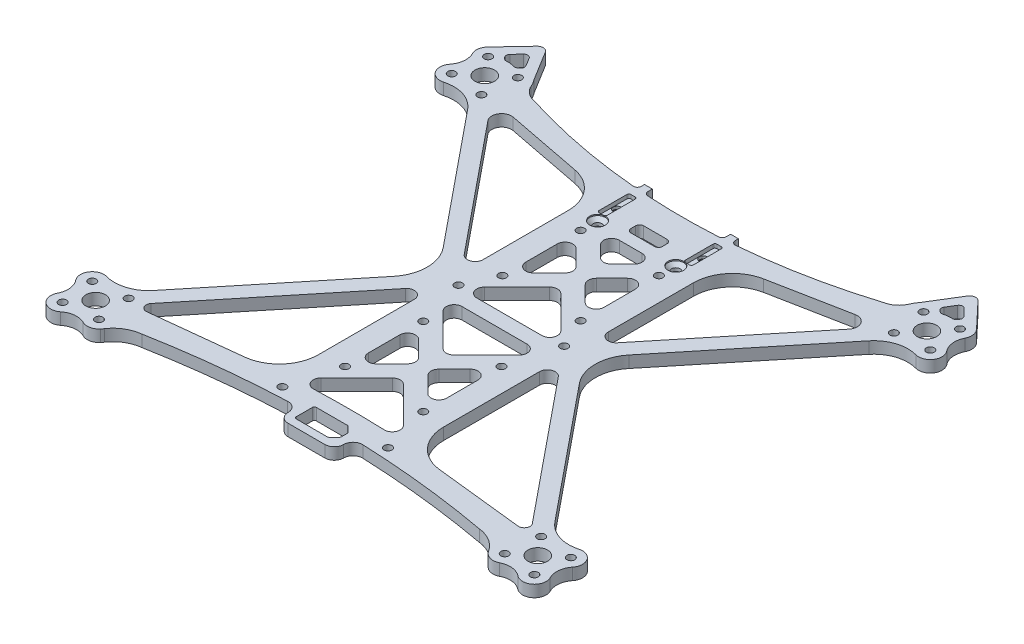
from build123d import *

# Parameters (mm, degrees)
SKETCH1_R                                      = 1
BASE_SHAPE_DEPTH                               = 2
CAMERA_MOUNT_POCKETS_DEPTH                     = 1
SKETCH3_R                                      = 1
THICKER_BASE_DEPTH                             = 1
SKETCH8_R                                      = 1
THICKER_CAMERA_MOUNT_POCKET_DEPTH              = 1
BATTERY_HOLDER_POCKETS_DEPTH                   = 1
BATTERY_HOLDER_HOLES_REACH                     = 55.417
SKETCH5_R                                      = 1.1
SKETCH7_R                                      = 1
SKETCH7_R_2                                    = 2.5
ARMS_DEPTH                                     = 3
MOTOR_PROTECTOR_FILLETS_R                      = 1
MOTOR_PROTECTOR_FILLETS_OF_ARMS_MIRROR_R       = 1
ARM_FILLETS_OUTER_R                            = 10
ARM_FILLETS_INNER_R                            = 2
ARM_LARGE_RADIUSES_REACH                       = 97.129
SKETCH11_W                                     = 2
SKETCH11_H                                     = 2.051249888
CAMERA_MOUNT_EXTENSION_DEPTH                   = 3
CAMERA_MOUNT_EXTENSION_FILLETS_R               = 1
CSK_FOR_M2_FLAT_HEAD_MACHINE_SCREW2_AT_2_COUNT = 2
CSK_FOR_M2_FLAT_HEAD_MACHINE_SCREW2_AT_2_PITCH = 22
CSK_FOR_M2_FLAT_HEAD_MACHINE_SCREW2_AT_3_COUNT = 2
CSK_FOR_M2_FLAT_HEAD_MACHINE_SCREW2_AT_3_PITCH = 10.373313116
CSK_FOR_M2_FLAT_HEAD_MACHINE_SCREW2_AT_4_COUNT = 2
CSK_FOR_M2_FLAT_HEAD_MACHINE_SCREW2_AT_4_PITCH = 23.400974873
CSK_FOR_M2_FLAT_HEAD_MACHINE_SCREW2_AT_5_COUNT = 2
CSK_FOR_M2_FLAT_HEAD_MACHINE_SCREW2_AT_5_PITCH = 30.341483566
CSK_FOR_M2_FLAT_HEAD_MACHINE_SCREW2_AT_6_COUNT = 2
CSK_FOR_M2_FLAT_HEAD_MACHINE_SCREW2_AT_6_PITCH = 36.886388072
CSK_FOR_M2_FLAT_HEAD_MACHINE_SCREW2_AT_7_COUNT = 2
CSK_FOR_M2_FLAT_HEAD_MACHINE_SCREW2_AT_7_PITCH = 50.559890229
CSK_FOR_M2_FLAT_HEAD_MACHINE_SCREW2_AT_8_COUNT = 2
CSK_FOR_M2_FLAT_HEAD_MACHINE_SCREW2_AT_8_PITCH = 54.738491941
CSK_FOR_M2_FLAT_HEAD_MACHINE_SCREW2_AT_9_COUNT = 2
CSK_FOR_M2_FLAT_HEAD_MACHINE_SCREW2_AT_9_PITCH = 70.557086816
CSK_FOR_M2_FLAT_HEAD_MACHINE_SCREW2_AT_1_COUNT = 2
CSK_FOR_M2_FLAT_HEAD_MACHINE_SCREW2_AT_1_PITCH = 73.60911968
CSK_FOR_M2_FLAT_HEAD_MACHINE_SCREW2_2_COUNT    = 2
CSK_FOR_M2_FLAT_HEAD_MACHINE_SCREW2_2_PITCH    = 38.132040334
CSK_FOR_M2_FLAT_HEAD_MACHINE_SCREW2_3_COUNT    = 2
CSK_FOR_M2_FLAT_HEAD_MACHINE_SCREW2_3_PITCH    = 45.255414041
CSK_FOR_M2_FLAT_HEAD_MACHINE_SCREW2_4_COUNT    = 2
CSK_FOR_M2_FLAT_HEAD_MACHINE_SCREW2_4_PITCH    = 83.087619415
CSK_FOR_M2_FLAT_HEAD_MACHINE_SCREW2_5_COUNT    = 2
CSK_FOR_M2_FLAT_HEAD_MACHINE_SCREW2_5_PITCH    = 86.588408578
CSK_FOR_M2_FLAT_HEAD_MACHINE_SCREW3_AT_2_COUNT = 2
CSK_FOR_M2_FLAT_HEAD_MACHINE_SCREW3_AT_2_PITCH = 20
GPS_CONNECTOR_HOLE_REACH                       = 97.129
TOP_WEIGHT_CUTS_REACH                          = 97.129
SKETCH29_W                                     = 14.2
SKETCH29_H                                     = 5
XT30_MATERIAL_DEPTH                            = 3
XT30_CUT_REACH                                 = 97.129
XT30_OUTSIDE_FILLETS_R                         = 2.4
XT30_INSIDE_FILLETS_R                          = 0.5


with BuildPart() as part:
    # Sketch1 → Base shape (new body)
    with BuildSketch(Plane(origin=(0, 0, 0), x_dir=(1, 0, 0), z_dir=(0, 1, 0))):
        with BuildLine():
            Line((-16, 47.925), (-16, -38.225))
            ThreePointArc((-16, -38.225), (-15.267766956, -39.99276695), (-13.500000008, -40.725))
            Line((-13.500000008, -40.725), (13.5, -40.725))
            ThreePointArc((13.5, -40.725), (15.267766953, -39.992766953), (16, -38.225))
            Line((16, -38.225), (16, 47.925))
            ThreePointArc((16, 47.925), (15.121320344, 50.046320344), (13, 50.925))
            Line((13, 50.925), (-13, 50.925))
            ThreePointArc((-13, 50.925), (-15.121320344, 50.046320344), (-16, 47.925))
        make_face()
        with Locations(Location((-13.5, -38.225, 0), (0, 0, 270))):
            Circle(SKETCH1_R, mode=Mode.SUBTRACT)
        with Locations(Location((13.5, -38.225, 0), (0, 0, 270))):
            Circle(SKETCH1_R, mode=Mode.SUBTRACT)
        with Locations(Location((10, -25.725, 0), (0, 0, 270))):
            Circle(SKETCH1_R, mode=Mode.SUBTRACT)
        with Locations(Location((-10, -25.725, 0), (0, 0, 270))):
            Circle(SKETCH1_R, mode=Mode.SUBTRACT)
        with Locations(Location((-10, -5.725, 0), (0, 0, 270))):
            Circle(SKETCH1_R, mode=Mode.SUBTRACT)
        with Locations(Location((10, -5.725, 0), (0, 0, 270))):
            Circle(SKETCH1_R, mode=Mode.SUBTRACT)
        with Locations(Location((-11, 44.825, 0), (0, 0, 270))):
            Circle(SKETCH1_R, mode=Mode.SUBTRACT)
        with Locations(Location((-10, 34.5, 0), (0, 0, 270))):
            Circle(SKETCH1_R, mode=Mode.SUBTRACT)
        with Locations(Location((10, 34.5, 0), (0, 0, 270))):
            Circle(SKETCH1_R, mode=Mode.SUBTRACT)
        with Locations(Location((10, 14.5, 0), (0, 0, 270))):
            Circle(SKETCH1_R, mode=Mode.SUBTRACT)
        with Locations(Location((-10, 14.5, 0), (0, 0, 270))):
            Circle(SKETCH1_R, mode=Mode.SUBTRACT)
        with Locations(Location((13.5, 6.775, 0), (0, 0, 270))):
            Circle(SKETCH1_R, mode=Mode.SUBTRACT)
        with Locations(Location((11, 44.825, 0), (0, 0, 270))):
            Circle(SKETCH1_R, mode=Mode.SUBTRACT)
        with Locations(Location((-13.5, 6.775, 0), (0, 0, 270))):
            Circle(SKETCH1_R, mode=Mode.SUBTRACT)
    extrude(amount=BASE_SHAPE_DEPTH)

    # Sketch2 → Camera mount pockets (cut)
    with BuildSketch(Plane.XZ.offset(-2)):
        with BuildLine():
            Line((11.55, -40.775), (10.45, -40.775))
            ThreePointArc((10.45, -40.775), (10.096446609, -40.921446609), (9.95, -41.275))
            Line((9.95, -41.275), (9.95, -48.375))
            ThreePointArc((9.95, -48.375), (10.096446609, -48.728553391), (10.45, -48.875))
            Line((10.45, -48.875), (11.55, -48.875))
            ThreePointArc((11.55, -48.875), (11.903553391, -48.728553391), (12.05, -48.375))
            Line((12.05, -48.375), (12.05, -41.275))
            ThreePointArc((12.05, -41.275), (11.903553391, -40.921446609), (11.55, -40.775))
        make_face()
        with BuildLine():
            Line((-11.55, -40.775), (-10.45, -40.775))
            ThreePointArc((-10.45, -40.775), (-10.096446609, -40.921446609), (-9.95, -41.275))
            Line((-9.95, -41.275), (-9.95, -48.375))
            ThreePointArc((-9.95, -48.375), (-10.096446609, -48.728553391), (-10.45, -48.875))
            Line((-10.45, -48.875), (-11.55, -48.875))
            ThreePointArc((-11.55, -48.875), (-11.903553391, -48.728553391), (-12.05, -48.375))
            Line((-12.05, -48.375), (-12.05, -41.275))
            ThreePointArc((-12.05, -41.275), (-11.903553391, -40.921446609), (-11.55, -40.775))
        make_face()
    extrude(amount=CAMERA_MOUNT_POCKETS_DEPTH, mode=Mode.SUBTRACT)

    # Sketch3 → Thicker base (add)
    with BuildSketch(Plane(origin=(0, 2, 0), x_dir=(1, 0, 0), z_dir=(0, 1, 0))):
        with BuildLine():
            Line((-16, 47.925), (-16, -38.225))
            ThreePointArc((-16, -38.225), (-15.267766953, -39.992766953), (-13.5, -40.725))
            Line((-13.5, -40.725), (13.5, -40.725))
            ThreePointArc((13.5, -40.725), (15.267766953, -39.992766953), (16, -38.225))
            Line((16, -38.225), (16, 47.925))
            ThreePointArc((16, 47.925), (15.121320344, 50.046320344), (13, 50.925))
            Line((13, 50.925), (-13, 50.925))
            ThreePointArc((-13, 50.925), (-15.121320344, 50.046320344), (-16, 47.925))
        make_face()
        with Locations(Location((10, 14.5, 0), (0, 0, 270))):
            Circle(SKETCH3_R, mode=Mode.SUBTRACT)
        with Locations(Location((10, 34.5, 0), (0, 0, 270))):
            Circle(SKETCH3_R, mode=Mode.SUBTRACT)
        with Locations(Location((-10, 34.5, 0), (0, 0, 270))):
            Circle(SKETCH3_R, mode=Mode.SUBTRACT)
        with Locations(Location((-10, 14.5, 0), (0, 0, 270))):
            Circle(SKETCH3_R, mode=Mode.SUBTRACT)
        with Locations(Location((13.5, 6.775, 0), (0, 0, 270))):
            Circle(SKETCH3_R, mode=Mode.SUBTRACT)
        with Locations(Location((10, -5.725, 0), (0, 0, 270))):
            Circle(SKETCH3_R, mode=Mode.SUBTRACT)
        with Locations(Location((10, -25.725, 0), (0, 0, 270))):
            Circle(SKETCH3_R, mode=Mode.SUBTRACT)
        with Locations(Location((-10, -25.725, 0), (0, 0, 270))):
            Circle(SKETCH3_R, mode=Mode.SUBTRACT)
        with Locations(Location((-10, -5.725, 0), (0, 0, 270))):
            Circle(SKETCH3_R, mode=Mode.SUBTRACT)
        with Locations(Location((13.5, -38.225, 0), (0, 0, 270))):
            Circle(SKETCH3_R, mode=Mode.SUBTRACT)
        with Locations(Location((-13.5, -38.225, 0), (0, 0, 270))):
            Circle(SKETCH3_R, mode=Mode.SUBTRACT)
        with Locations(Location((-13.5, 6.775, 0), (0, 0, 270))):
            Circle(SKETCH3_R, mode=Mode.SUBTRACT)
        with BuildLine():
            Line((-11.55, 48.875), (-10.45, 48.875))
            ThreePointArc((-10.45, 48.875), (-10.096446609, 48.728553391), (-9.95, 48.375))
            Line((-9.95, 48.375), (-9.95, 41.275))
            ThreePointArc((-9.95, 41.275), (-10.096446609, 40.921446609), (-10.45, 40.775))
            Line((-10.45, 40.775), (-11.55, 40.775))
            ThreePointArc((-11.55, 40.775), (-11.903553391, 40.921446609), (-12.05, 41.275))
            Line((-12.05, 41.275), (-12.05, 48.375))
            ThreePointArc((-12.05, 48.375), (-11.903553391, 48.728553391), (-11.55, 48.875))
        make_face(mode=Mode.SUBTRACT)
        with BuildLine():
            Line((10.45, 48.875), (11.55, 48.875))
            ThreePointArc((11.55, 48.875), (11.903553391, 48.728553391), (12.05, 48.375))
            Line((12.05, 48.375), (12.05, 41.275))
            ThreePointArc((12.05, 41.275), (11.903553391, 40.921446609), (11.55, 40.775))
            Line((11.55, 40.775), (10.45, 40.775))
            ThreePointArc((10.45, 40.775), (10.096446609, 40.921446609), (9.95, 41.275))
            Line((9.95, 41.275), (9.95, 48.375))
            ThreePointArc((9.95, 48.375), (10.096446609, 48.728553391), (10.45, 48.875))
        make_face(mode=Mode.SUBTRACT)
    extrude(amount=THICKER_BASE_DEPTH)

    # Sketch8 → Thicker camera mount pocket (add)
    with BuildSketch(Plane(origin=(0, 1, 0), x_dir=(1, 0, 0), z_dir=(0, 1, 0))):
        with BuildLine():
            Line((-9.95, 41.275), (-9.95, 48.375))
            ThreePointArc((-9.95, 48.375), (-10.096446609, 48.728553391), (-10.45, 48.875))
            Line((-10.45, 48.875), (-11.55, 48.875))
            ThreePointArc((-11.55, 48.875), (-11.903553391, 48.728553391), (-12.05, 48.375))
            Line((-12.05, 48.375), (-12.05, 41.275))
            ThreePointArc((-12.05, 41.275), (-11.903553391, 40.921446609), (-11.55, 40.775))
            Line((-11.55, 40.775), (-10.45, 40.775))
            ThreePointArc((-10.45, 40.775), (-10.096446609, 40.921446609), (-9.95, 41.275))
        make_face()
        with Locations(Location((-11, 44.825, 0), (0, 0, 270))):
            Circle(SKETCH8_R, mode=Mode.SUBTRACT)
        with BuildLine():
            Line((11.55, 48.875), (10.45, 48.875))
            ThreePointArc((10.45, 48.875), (10.096446609, 48.728553391), (9.95, 48.375))
            Line((9.95, 48.375), (9.95, 41.275))
            ThreePointArc((9.95, 41.275), (10.096446609, 40.921446609), (10.45, 40.775))
            Line((10.45, 40.775), (11.55, 40.775))
            ThreePointArc((11.55, 40.775), (11.903553391, 40.921446609), (12.05, 41.275))
            Line((12.05, 41.275), (12.05, 48.375))
            ThreePointArc((12.05, 48.375), (11.903553391, 48.728553391), (11.55, 48.875))
        make_face()
        with Locations(Location((11, 44.825, 0), (0, 0, 270))):
            Circle(SKETCH8_R, mode=Mode.SUBTRACT)
    extrude(amount=THICKER_CAMERA_MOUNT_POCKET_DEPTH)

    # Sketch4 → Battery holder pockets (cut)
    with BuildSketch(Plane.XZ):
        with BuildLine():
            Line((-13.55, -37.275), (-6.45, -37.275))
            ThreePointArc((-6.45, -37.275), (-6.096446609, -37.421446609), (-5.95, -37.775))
            Line((-5.95, -37.775), (-5.95, -39.875))
            ThreePointArc((-5.95, -39.875), (-6.096446609, -40.228553391), (-6.45, -40.375))
            Line((-6.45, -40.375), (-13.55, -40.375))
            ThreePointArc((-13.55, -40.375), (-13.903553391, -40.228553391), (-14.05, -39.875))
            Line((-14.05, -39.875), (-14.05, -37.775))
            ThreePointArc((-14.05, -37.775), (-13.903553391, -37.421446609), (-13.55, -37.275))
        make_face()
        with BuildLine():
            Line((13.55, -37.275), (6.45, -37.275))
            ThreePointArc((6.45, -37.275), (6.096446609, -37.421446609), (5.95, -37.775))
            Line((5.95, -37.775), (5.95, -39.875))
            ThreePointArc((5.95, -39.875), (6.096446609, -40.228553391), (6.45, -40.375))
            Line((6.45, -40.375), (13.55, -40.375))
            ThreePointArc((13.55, -40.375), (13.903553391, -40.228553391), (14.05, -39.875))
            Line((14.05, -39.875), (14.05, -37.775))
            ThreePointArc((14.05, -37.775), (13.903553391, -37.421446609), (13.55, -37.275))
        make_face()
    extrude(amount=-BATTERY_HOLDER_POCKETS_DEPTH, mode=Mode.SUBTRACT)

    # Sketch5 → Battery holder holes (cut, up to next)
    with BuildSketch(Plane.XZ.offset(-1), mode=Mode.PRIVATE) as battery_holder_holes_sk1:
        with Locations(Location((-10, -38.825, 0), (0, 0, 270))):
            Circle(SKETCH5_R)
    battery_holder_holes_tool1 = extrude(battery_holder_holes_sk1.sketch, amount=-BATTERY_HOLDER_HOLES_REACH, mode=Mode.PRIVATE) & part.part
    # Sketch5 → Battery holder holes (cut, up to next)
    with BuildSketch(Plane.XZ.offset(-1), mode=Mode.PRIVATE) as battery_holder_holes_sk2:
        with Locations(Location((10, -38.825, 0), (0, 0, 90))):
            Circle(SKETCH5_R)
    battery_holder_holes_tool2 = extrude(battery_holder_holes_sk2.sketch, amount=-BATTERY_HOLDER_HOLES_REACH, mode=Mode.PRIVATE) & part.part
    add(battery_holder_holes_tool1.solids().sort_by_distance((-10, 1, -38.825))[0], mode=Mode.SUBTRACT)
    add(battery_holder_holes_tool2.solids().sort_by_distance((10, 1, -38.825))[0], mode=Mode.SUBTRACT)

    # Sketch7 → Arms (add)
    with BuildSketch(Plane(origin=(0, 3, 0), x_dir=(1, 0, 0), z_dir=(0, 1, 0))):
        with BuildLine():
            ThreePointArc((-62.47202097, 63.210050524), (-63.258058205, 61.582626867), (-62.966574166, 59.798979103))
            ThreePointArc((-62.966574166, 59.798979103), (-62.468882045, 57.110284473), (-63.500396089, 54.577942665))
            ThreePointArc((-63.500396089, 54.577942665), (-63.655904224, 51.058225308), (-60.358324379, 49.817838185))
            ThreePointArc((-60.358324379, 49.817838185), (-55.380575233, 49.713451564), (-51.267187751, 46.908290863))
            Line((-51.267187751, 46.908290863), (-18.579439537, 6.775))
            Line((-18.579439537, 6.775), (-51.267188018, -33.358291191))
            ThreePointArc((-51.267188018, -33.358291191), (-55.380575456, -36.163451636), (-60.358324423, -36.267838173))
            ThreePointArc((-60.358324423, -36.267838173), (-63.655904377, -37.50822554), (-63.500395772, -41.027943063))
            ThreePointArc((-63.500395772, -41.027943063), (-62.468882018, -43.56028473), (-62.966574169, -46.248979109))
            ThreePointArc((-62.966574169, -46.248979109), (-62.183650893, -49.928259993), (-58.422057259, -49.950396028))
            ThreePointArc((-58.422057259, -49.950396028), (-55.889715341, -48.918882026), (-53.20102065, -49.416574291))
            ThreePointArc((-53.20102065, -49.416574291), (-51.223429139, -49.673402436), (-49.521740056, -48.633650953))
            ThreePointArc((-49.521740056, -48.633650953), (-49.300362763, -48.35048365), (-49.090468591, -48.0587028))
            ThreePointArc((-49.090468591, -48.0587028), (-46.497237316, -45.629566953), (-43.128728346, -44.498772221))
            Line((-43.128728346, -44.498772221), (-8.785404431, -40.725))
            Line((-8.785404431, -40.725), (-13.5, -40.725))
            ThreePointArc((-13.5, -40.725), (-15.267766953, -39.992766953), (-16, -38.225))
            Line((-16, -38.225), (-16, -35.481651999))
            Line((-16, -35.481651999), (-47.421727421, -38.934388326))
            ThreePointArc((-47.421727421, -38.934388326), (-48.865270105, -38.180123465), (-48.71471318, -36.558376391))
            Line((-48.71471318, -36.558376391), (-16, 3.608021458))
            Line((-16, 3.608021458), (-16, 9.941978542))
            Line((-16, 9.941978542), (-46.12379651, 46.92730648))
            ThreePointArc((-46.12379651, 46.92730648), (-46.330256338, 49.790447374), (-43.708856482, 50.960261136))
            Line((-43.708856482, 50.960261136), (-16, 45.579923059))
            Line((-16, 45.579923059), (-16, 47.925))
            ThreePointArc((-16, 47.925), (-15.121320344, 50.046320344), (-13, 50.925))
            Line((-13, 50.925), (-12.05, 50.925))
            Line((-12.05, 50.925), (-44.71964318, 57.268593618))
            ThreePointArc((-44.71964318, 57.268593618), (-46.834336642, 58.247932432), (-48.250737643, 60.098565069))
            ThreePointArc((-48.250737643, 60.098565069), (-48.759231498, 61.091350891), (-49.386626396, 62.01361188))
            Line((-49.386626396, 62.01361188), (-53.977644794, 69.465912288))
            ThreePointArc((-53.977644794, 69.465912288), (-55.102179452, 70.171366822), (-56.346210857, 69.708084878))
            Line((-56.346210857, 69.708084878), (-62.47202097, 63.210050524))
        make_face()
        with Locations(Location((-61.1521734, -39.160899493, 0), (0, 0, 270))):
            Circle(SKETCH7_R, mode=Mode.SUBTRACT)
        with Locations(Location((-60.289100507, -47.6021734, 0), (0, 0, 270))):
            Circle(SKETCH7_R, mode=Mode.SUBTRACT)
        with Locations(Location((-56.5, -42.95, 0), (0, 0, 270))):
            Circle(SKETCH7_R_2, mode=Mode.SUBTRACT)
        with Locations(Location((-52.710899493, -38.2978266, 0), (0, 0, 270))):
            Circle(SKETCH7_R, mode=Mode.SUBTRACT)
        with Locations(Location((-51.8478266, -46.739100507, 0), (0, 0, 270))):
            Circle(SKETCH7_R, mode=Mode.SUBTRACT)
        with Locations(Location((-61.1521734, 52.710899493, 0), (0, 0, 270))):
            Circle(SKETCH7_R, mode=Mode.SUBTRACT)
        with Locations(Location((-60.289100507, 61.1521734, 0), (0, 0, 270))):
            Circle(SKETCH7_R, mode=Mode.SUBTRACT)
        with BuildLine():
            ThreePointArc((-57.563239181, 62.40504212), (-58.036436329, 63.133461896), (-58.698484556, 63.69578125))
            Line((-58.698484556, 63.69578125), (-55.4073218, 67.186925811))
            Line((-55.4073218, 67.186925811), (-52.890772261, 63.101975255))
            ThreePointArc((-52.890772261, 63.101975255), (-53.65292006, 62.685271953), (-54.26373867, 62.067686707))
            ThreePointArc((-54.26373867, 62.067686707), (-55.889715305, 62.468882022), (-57.563239181, 62.40504212))
        make_face(mode=Mode.SUBTRACT)
        with Locations(Location((-56.5, 56.5, 0), (0, 0, 270))):
            Circle(SKETCH7_R_2, mode=Mode.SUBTRACT)
        with Locations(Location((-52.710899493, 51.8478266, 0), (0, 0, 270))):
            Circle(SKETCH7_R, mode=Mode.SUBTRACT)
        with Locations(Location((-51.8478266, 60.289100507, 0), (0, 0, 270))):
            Circle(SKETCH7_R, mode=Mode.SUBTRACT)
    arms = extrude(amount=-ARMS_DEPTH)

    # Motor protector fillets
    motor_protector_fillets_edges = [part.edges().sort_by_distance(p)[0] for p in [
        (-58.698484556, 1.5, -63.69578125),
        (-57.563239181, 1.5, -62.40504212),
        (-54.26373867, 1.5, -62.067686707),
        (-52.890772261, 1.5, -63.101975255),
        (-55.4073218, 1.5, -67.186925811),
    ]]
    fillet(motor_protector_fillets_edges, radius=MOTOR_PROTECTOR_FILLETS_R)

    # Arms mirror: Arms across plane
    add(arms.mirror(Plane(origin=(0, 0, 0), x_dir=(0, 0, 1), z_dir=(1, 0, 0))))

    # Motor protector fillets of Arms mirror
    motor_protector_fillets_of_arms_mirror_edges = [part.edges().sort_by_distance(p)[0] for p in [
        (58.698484556, 1.5, -63.69578125),
        (57.563239181, 1.5, -62.40504212),
        (54.26373867, 1.5, -62.067686707),
        (52.890772261, 1.5, -63.101975255),
        (55.4073218, 1.5, -67.186925811),
    ]]
    fillet(motor_protector_fillets_of_arms_mirror_edges, radius=MOTOR_PROTECTOR_FILLETS_OF_ARMS_MIRROR_R)

    # Arm fillets outer
    arm_fillets_outer_edges = [part.edges().sort_by_distance(p)[0] for p in [
        (-16, 1.5, -45.579923059),
        (-16, 1.5, 35.481651999),
        (-18.579439537, 1.5, -6.775),
        (16, 1.5, -45.579923059),
        (16, 1.5, 35.481651999),
        (18.579439537, 1.5, -6.775),
    ]]
    fillet(arm_fillets_outer_edges, radius=ARM_FILLETS_OUTER_R)

    # Arm fillets inner
    arm_fillets_inner_edges = [part.edges().sort_by_distance(p)[0] for p in [
        (-16, 1.5, -9.941978542),
        (-16, 1.5, -3.608021458),
        (16, 1.5, -9.941978542),
        (16, 1.5, -3.608021458),
    ]]
    fillet(arm_fillets_inner_edges, radius=ARM_FILLETS_INNER_R)

    # Sketch9 → Arm large radiuses (cut, up to next)
    with BuildSketch(Plane.XZ, mode=Mode.PRIVATE) as arm_large_radiuses_sk1:
        with BuildLine():
            Line((-44.719643635, -57.268593707), (-12.05, -50.925))
            ThreePointArc((-12.05, -50.925), (-28.561484641, -53.186979524), (-44.719643635, -57.268593707))
        make_face()
    arm_large_radiuses_tool1 = extrude(arm_large_radiuses_sk1.sketch, amount=-ARM_LARGE_RADIUSES_REACH, mode=Mode.PRIVATE) & part.part
    # Sketch9 → Arm large radiuses (cut, up to next)
    with BuildSketch(Plane.XZ, mode=Mode.PRIVATE) as arm_large_radiuses_sk2:
        with BuildLine():
            ThreePointArc((12.05, -50.925), (6.029884499, -50.561064749), (0, -50.439687451))
            Line((0, -50.439687451), (0, -50.925))
            Line((0, -50.925), (12.05, -50.925))
        make_face()
    arm_large_radiuses_tool2 = extrude(arm_large_radiuses_sk2.sketch, amount=-ARM_LARGE_RADIUSES_REACH, mode=Mode.PRIVATE) & part.part
    # Sketch9 → Arm large radiuses (cut, up to next)
    with BuildSketch(Plane.XZ, mode=Mode.PRIVATE) as arm_large_radiuses_sk3:
        with BuildLine():
            Line((0, -50.925), (0, -50.439687451))
            ThreePointArc((0, -50.439687451), (-6.029884499, -50.561064749), (-12.05, -50.925))
            Line((-12.05, -50.925), (0, -50.925))
        make_face()
    arm_large_radiuses_tool3 = extrude(arm_large_radiuses_sk3.sketch, amount=-ARM_LARGE_RADIUSES_REACH, mode=Mode.PRIVATE) & part.part
    # Sketch9 → Arm large radiuses (cut, up to next)
    with BuildSketch(Plane.XZ, mode=Mode.PRIVATE) as arm_large_radiuses_sk4:
        with BuildLine():
            ThreePointArc((12.05, -50.925), (6.029884499, -50.561064749), (0, -50.439687451))
            Line((0, -50.439687451), (0, -50.925))
            Line((0, -50.925), (12.05, -50.925))
        make_face()
    arm_large_radiuses_tool4 = extrude(arm_large_radiuses_sk4.sketch, amount=-ARM_LARGE_RADIUSES_REACH, mode=Mode.PRIVATE) & part.part
    # Sketch9 → Arm large radiuses (cut, up to next)
    with BuildSketch(Plane.XZ, mode=Mode.PRIVATE) as arm_large_radiuses_sk5:
        with BuildLine():
            Line((0, -50.925), (0, -50.439687451))
            ThreePointArc((0, -50.439687451), (-6.029884499, -50.561064749), (-12.05, -50.925))
            Line((-12.05, -50.925), (0, -50.925))
        make_face()
    arm_large_radiuses_tool5 = extrude(arm_large_radiuses_sk5.sketch, amount=-ARM_LARGE_RADIUSES_REACH, mode=Mode.PRIVATE) & part.part
    # Sketch9 → Arm large radiuses (cut, up to next)
    with BuildSketch(Plane.XZ, mode=Mode.PRIVATE) as arm_large_radiuses_sk6:
        with BuildLine():
            ThreePointArc((44.719643635, -57.268593707), (28.561484641, -53.186979524), (12.05, -50.925))
            Line((12.05, -50.925), (44.719643635, -57.268593707))
        make_face()
    arm_large_radiuses_tool6 = extrude(arm_large_radiuses_sk6.sketch, amount=-ARM_LARGE_RADIUSES_REACH, mode=Mode.PRIVATE) & part.part
    # Sketch9 → Arm large radiuses (cut, up to next)
    with BuildSketch(Plane.XZ, mode=Mode.PRIVATE) as arm_large_radiuses_sk7:
        with BuildLine():
            ThreePointArc((-43.128728341, 44.49877222), (-26.025557334, 41.988582242), (-8.785404431, 40.725))
            Line((-8.785404431, 40.725), (-43.128728341, 44.49877222))
        make_face()
    arm_large_radiuses_tool7 = extrude(arm_large_radiuses_sk7.sketch, amount=-ARM_LARGE_RADIUSES_REACH, mode=Mode.PRIVATE) & part.part
    # Sketch9 → Arm large radiuses (cut, up to next)
    with BuildSketch(Plane.XZ, mode=Mode.PRIVATE) as arm_large_radiuses_sk8:
        with BuildLine():
            Line((8.785404431, 40.725), (0, 40.725))
            Line((0, 40.725), (0, 40.562980124))
            ThreePointArc((0, 40.562980124), (4.393449142, 40.603488537), (8.785404431, 40.725))
        make_face()
    arm_large_radiuses_tool8 = extrude(arm_large_radiuses_sk8.sketch, amount=-ARM_LARGE_RADIUSES_REACH, mode=Mode.PRIVATE) & part.part
    # Sketch9 → Arm large radiuses (cut, up to next)
    with BuildSketch(Plane.XZ, mode=Mode.PRIVATE) as arm_large_radiuses_sk9:
        with BuildLine():
            Line((0, 40.562980124), (0, 40.725))
            Line((0, 40.725), (-8.785404431, 40.725))
            ThreePointArc((-8.785404431, 40.725), (-4.393449142, 40.603488537), (0, 40.562980124))
        make_face()
    arm_large_radiuses_tool9 = extrude(arm_large_radiuses_sk9.sketch, amount=-ARM_LARGE_RADIUSES_REACH, mode=Mode.PRIVATE) & part.part
    # Sketch9 → Arm large radiuses (cut, up to next)
    with BuildSketch(Plane.XZ, mode=Mode.PRIVATE) as arm_large_radiuses_sk10:
        with BuildLine():
            Line((8.785404431, 40.725), (0, 40.725))
            Line((0, 40.725), (0, 40.562980124))
            ThreePointArc((0, 40.562980124), (4.393449142, 40.603488537), (8.785404431, 40.725))
        make_face()
    arm_large_radiuses_tool10 = extrude(arm_large_radiuses_sk10.sketch, amount=-ARM_LARGE_RADIUSES_REACH, mode=Mode.PRIVATE) & part.part
    # Sketch9 → Arm large radiuses (cut, up to next)
    with BuildSketch(Plane.XZ, mode=Mode.PRIVATE) as arm_large_radiuses_sk11:
        with BuildLine():
            Line((0, 40.562980124), (0, 40.725))
            Line((0, 40.725), (-8.785404431, 40.725))
            ThreePointArc((-8.785404431, 40.725), (-4.393449142, 40.603488537), (0, 40.562980124))
        make_face()
    arm_large_radiuses_tool11 = extrude(arm_large_radiuses_sk11.sketch, amount=-ARM_LARGE_RADIUSES_REACH, mode=Mode.PRIVATE) & part.part
    # Sketch9 → Arm large radiuses (cut, up to next)
    with BuildSketch(Plane.XZ, mode=Mode.PRIVATE) as arm_large_radiuses_sk12:
        with BuildLine():
            Line((43.128728341, 44.49877222), (8.785404431, 40.725))
            ThreePointArc((8.785404431, 40.725), (26.025557334, 41.988582242), (43.128728341, 44.49877222))
        make_face()
    arm_large_radiuses_tool12 = extrude(arm_large_radiuses_sk12.sketch, amount=-ARM_LARGE_RADIUSES_REACH, mode=Mode.PRIVATE) & part.part
    add(arm_large_radiuses_tool1.solids().sort_by_distance((-28.455506, 0, -53.732773))[0], mode=Mode.SUBTRACT)
    add(arm_large_radiuses_tool2.solids().sort_by_distance((4.519727, 0, -50.730848))[0], mode=Mode.SUBTRACT)
    add(arm_large_radiuses_tool3.solids().sort_by_distance((-4.519727, 0, -50.730848))[0], mode=Mode.SUBTRACT)
    add(arm_large_radiuses_tool4.solids().sort_by_distance((4.519727, 0, -50.730848))[0], mode=Mode.SUBTRACT)
    add(arm_large_radiuses_tool5.solids().sort_by_distance((-4.519727, 0, -50.730848))[0], mode=Mode.SUBTRACT)
    add(arm_large_radiuses_tool6.solids().sort_by_distance((28.455506, 0, -53.732773))[0], mode=Mode.SUBTRACT)
    add(arm_large_radiuses_tool7.solids().sort_by_distance((-25.984466, 0, 42.362536))[0], mode=Mode.SUBTRACT)
    add(arm_large_radiuses_tool8.solids().sort_by_distance((3.294676, 0, 40.66019))[0], mode=Mode.SUBTRACT)
    add(arm_large_radiuses_tool9.solids().sort_by_distance((-3.294676, 0, 40.66019))[0], mode=Mode.SUBTRACT)
    add(arm_large_radiuses_tool10.solids().sort_by_distance((3.294676, 0, 40.66019))[0], mode=Mode.SUBTRACT)
    add(arm_large_radiuses_tool11.solids().sort_by_distance((-3.294676, 0, 40.66019))[0], mode=Mode.SUBTRACT)
    add(arm_large_radiuses_tool12.solids().sort_by_distance((25.984466, 0, 42.362536))[0], mode=Mode.SUBTRACT)

    # Sketch11 → Camera mount extension (add)
    with BuildSketch(Plane.XZ):
        with Locations((-11, -51.799375056)):
            Rectangle(SKETCH11_W, SKETCH11_H)
        with Locations((11, -51.799375056)):
            Rectangle(SKETCH11_W, SKETCH11_H)
    extrude(amount=-CAMERA_MOUNT_EXTENSION_DEPTH)

    # Camera mount extension fillets
    camera_mount_extension_fillets_edges = [part.edges().sort_by_distance(p)[0] for p in [
        (-12, 1.5, -50.92097439),
        (-10, 1.5, -50.773750112),
        (12, 1.5, -50.92097439),
        (10, 1.5, -50.773750112),
    ]]
    fillet(camera_mount_extension_fillets_edges, radius=CAMERA_MOUNT_EXTENSION_FILLETS_R)

    # Sketch21 → CSK for M2 Flat Head Machine Screw2 (revolve, cut)
    with BuildSketch(Plane(origin=(11, 0, -44.825), x_dir=(0, 0, -1), z_dir=(1, 0, 0))):
        Polygon((0, 0), (0, 3), (1, 3), (1, 1.3), (2, 0.3), (2, 0), align=None)
    csk_for_m2_flat_head_machine_screw2 = revolve(axis=Axis((11, -6.35, -44.825), (0, 1, 0)), mode=Mode.SUBTRACT)

    # CSK for M2 Flat Head Machine Screw2 at 2: CSK for M2 Flat Head Machine Screw2 ×2
    with Locations(*[(-i * CSK_FOR_M2_FLAT_HEAD_MACHINE_SCREW2_AT_2_PITCH, 0, 0) for i in range(1, CSK_FOR_M2_FLAT_HEAD_MACHINE_SCREW2_AT_2_COUNT)]):
        add(csk_for_m2_flat_head_machine_screw2, mode=Mode.SUBTRACT)

    # CSK for M2 Flat Head Machine Screw2 at 3: CSK for M2 Flat Head Machine Screw2 ×2
    with Locations(*[Vector(-0.09640121616203635, 0, 0.9953425568729996) * (i * CSK_FOR_M2_FLAT_HEAD_MACHINE_SCREW2_AT_3_PITCH) for i in range(1, CSK_FOR_M2_FLAT_HEAD_MACHINE_SCREW2_AT_3_COUNT)]):
        add(csk_for_m2_flat_head_machine_screw2, mode=Mode.SUBTRACT)

    # CSK for M2 Flat Head Machine Screw2 at 4: CSK for M2 Flat Head Machine Screw2 ×2
    with Locations(*[Vector(-0.8973985107073349, 0, 0.44122093443110505) * (i * CSK_FOR_M2_FLAT_HEAD_MACHINE_SCREW2_AT_4_PITCH) for i in range(1, CSK_FOR_M2_FLAT_HEAD_MACHINE_SCREW2_AT_4_COUNT)]):
        add(csk_for_m2_flat_head_machine_screw2, mode=Mode.SUBTRACT)

    # CSK for M2 Flat Head Machine Screw2 at 5: CSK for M2 Flat Head Machine Screw2 ×2
    with Locations(*[Vector(-0.03295817746739682, 0, 0.9994567316987902) * (i * CSK_FOR_M2_FLAT_HEAD_MACHINE_SCREW2_AT_5_PITCH) for i in range(1, CSK_FOR_M2_FLAT_HEAD_MACHINE_SCREW2_AT_5_COUNT)]):
        add(csk_for_m2_flat_head_machine_screw2, mode=Mode.SUBTRACT)

    # CSK for M2 Flat Head Machine Screw2 at 6: CSK for M2 Flat Head Machine Screw2 ×2
    with Locations(*[Vector(-0.5693157041832146, 0, 0.8221189871121884) * (i * CSK_FOR_M2_FLAT_HEAD_MACHINE_SCREW2_AT_6_PITCH) for i in range(1, CSK_FOR_M2_FLAT_HEAD_MACHINE_SCREW2_AT_6_COUNT)]):
        add(csk_for_m2_flat_head_machine_screw2, mode=Mode.SUBTRACT)

    # CSK for M2 Flat Head Machine Screw2 at 7: CSK for M2 Flat Head Machine Screw2 ×2
    with Locations(*[Vector(-0.019778523953761964, 0, 0.99980438586266) * (i * CSK_FOR_M2_FLAT_HEAD_MACHINE_SCREW2_AT_7_PITCH) for i in range(1, CSK_FOR_M2_FLAT_HEAD_MACHINE_SCREW2_AT_7_COUNT)]):
        add(csk_for_m2_flat_head_machine_screw2, mode=Mode.SUBTRACT)

    # CSK for M2 Flat Head Machine Screw2 at 8: CSK for M2 Flat Head Machine Screw2 ×2
    with Locations(*[Vector(-0.3836422827020339, 0, 0.9234817805041812) * (i * CSK_FOR_M2_FLAT_HEAD_MACHINE_SCREW2_AT_8_PITCH) for i in range(1, CSK_FOR_M2_FLAT_HEAD_MACHINE_SCREW2_AT_8_COUNT)]):
        add(csk_for_m2_flat_head_machine_screw2, mode=Mode.SUBTRACT)

    # CSK for M2 Flat Head Machine Screw2 at 9: CSK for M2 Flat Head Machine Screw2 ×2
    with Locations(*[Vector(-0.014172920752862996, 0, 0.9998995591144808) * (i * CSK_FOR_M2_FLAT_HEAD_MACHINE_SCREW2_AT_9_PITCH) for i in range(1, CSK_FOR_M2_FLAT_HEAD_MACHINE_SCREW2_AT_9_COUNT)]):
        add(csk_for_m2_flat_head_machine_screw2, mode=Mode.SUBTRACT)

    # CSK for M2 Flat Head Machine Screw2 at 1: CSK for M2 Flat Head Machine Screw2 ×2
    with Locations(*[Vector(-0.28529073695512397, 0, 0.958441023437333) * (i * CSK_FOR_M2_FLAT_HEAD_MACHINE_SCREW2_AT_1_PITCH) for i in range(1, CSK_FOR_M2_FLAT_HEAD_MACHINE_SCREW2_AT_1_COUNT)]):
        add(csk_for_m2_flat_head_machine_screw2, mode=Mode.SUBTRACT)

    # CSK for M2 Flat Head Machine Screw2  2: CSK for M2 Flat Head Machine Screw2 ×2
    with Locations(*[Vector(0.06556166358084844, 0, 0.9978485197005164) * (i * CSK_FOR_M2_FLAT_HEAD_MACHINE_SCREW2_2_PITCH) for i in range(1, CSK_FOR_M2_FLAT_HEAD_MACHINE_SCREW2_2_COUNT)]):
        add(csk_for_m2_flat_head_machine_screw2, mode=Mode.SUBTRACT)

    # CSK for M2 Flat Head Machine Screw2  3: CSK for M2 Flat Head Machine Screw2 ×2
    with Locations(*[Vector(-0.5413716904222198, 0, 0.840783380431243) * (i * CSK_FOR_M2_FLAT_HEAD_MACHINE_SCREW2_3_PITCH) for i in range(1, CSK_FOR_M2_FLAT_HEAD_MACHINE_SCREW2_3_COUNT)]):
        add(csk_for_m2_flat_head_machine_screw2, mode=Mode.SUBTRACT)

    # CSK for M2 Flat Head Machine Screw2  4: CSK for M2 Flat Head Machine Screw2 ×2
    with Locations(*[Vector(0.03008871860346097, 0, 0.9995472320069732) * (i * CSK_FOR_M2_FLAT_HEAD_MACHINE_SCREW2_4_PITCH) for i in range(1, CSK_FOR_M2_FLAT_HEAD_MACHINE_SCREW2_4_COUNT)]):
        add(csk_for_m2_flat_head_machine_screw2, mode=Mode.SUBTRACT)

    # CSK for M2 Flat Head Machine Screw2  5: CSK for M2 Flat Head Machine Screw2 ×2
    with Locations(*[Vector(-0.2829478033199505, 0, 0.959135308804975) * (i * CSK_FOR_M2_FLAT_HEAD_MACHINE_SCREW2_5_PITCH) for i in range(1, CSK_FOR_M2_FLAT_HEAD_MACHINE_SCREW2_5_COUNT)]):
        add(csk_for_m2_flat_head_machine_screw2, mode=Mode.SUBTRACT)

    # Sketch23 → CSK for M2 Flat Head Machine Screw3 (revolve, cut)
    with BuildSketch(Plane(origin=(-10, 3, -38.825), x_dir=(0, 0, 1), z_dir=(1, 0, 0))):
        Polygon((0, 0), (0, 3), (1, 3), (1, 1.3), (2, 0.3), (2, 0), align=None)
    csk_for_m2_flat_head_machine_screw3 = revolve(axis=Axis((-10, 9.35, -38.825), (0, -1, 0)), mode=Mode.SUBTRACT)

    # CSK for M2 Flat Head Machine Screw3 at 2: CSK for M2 Flat Head Machine Screw3 ×2
    with Locations(*[(i * CSK_FOR_M2_FLAT_HEAD_MACHINE_SCREW3_AT_2_PITCH, 0, 0) for i in range(1, CSK_FOR_M2_FLAT_HEAD_MACHINE_SCREW3_AT_2_COUNT)]):
        add(csk_for_m2_flat_head_machine_screw3, mode=Mode.SUBTRACT)

    # Sketch24 → GPS connector hole (cut, up to next)
    with BuildSketch(Plane.XZ, mode=Mode.PRIVATE) as gps_connector_hole_sk1:
        with BuildLine():
            Line((-3, -40.375), (3, -40.375))
            ThreePointArc((3, -40.375), (3.707106781, -40.667893219), (4, -41.375))
            Line((4, -41.375), (4, -42.575))
            ThreePointArc((4, -42.575), (3.707106781, -43.282106781), (3, -43.575))
            Line((3, -43.575), (-3, -43.575))
            ThreePointArc((-3, -43.575), (-3.707106781, -43.282106781), (-4, -42.575))
            Line((-4, -42.575), (-4, -41.375))
            ThreePointArc((-4, -41.375), (-3.707106781, -40.667893219), (-3, -40.375))
        make_face()
    gps_connector_hole_tool1 = extrude(gps_connector_hole_sk1.sketch, amount=-GPS_CONNECTOR_HOLE_REACH, mode=Mode.PRIVATE) & part.part
    add(gps_connector_hole_tool1.solids().sort_by_distance((0, 0, -41.975))[0], mode=Mode.SUBTRACT)

    # Sketch26 → Top weight cuts (cut, up to next)
    with BuildSketch(Plane.XZ, mode=Mode.PRIVATE) as top_weight_cuts_sk1:
        with BuildLine():
            Line((-10, 19.725), (-10, 11.725))
            ThreePointArc((-10, 11.725), (-8.765366865, 9.877240935), (-6.585786438, 10.310786438))
            Line((-6.585786438, 10.310786438), (-2.585786438, 14.310786438))
            ThreePointArc((-2.585786438, 14.310786438), (-2, 15.725), (-2.585786438, 17.139213562))
            Line((-2.585786438, 17.139213562), (-6.585786438, 21.139213562))
            ThreePointArc((-6.585786438, 21.139213562), (-8.765366865, 21.572759065), (-10, 19.725))
        make_face()
    top_weight_cuts_tool1 = extrude(top_weight_cuts_sk1.sketch, amount=-TOP_WEIGHT_CUTS_REACH, mode=Mode.PRIVATE) & part.part
    # Sketch26 → Top weight cuts (cut, up to next)
    with BuildSketch(Plane.XZ, mode=Mode.PRIVATE) as top_weight_cuts_sk2:
        with BuildLine():
            ThreePointArc((-9.734505856, 0.918097054), (-10.168051359, -1.261483373), (-8.320292294, -2.496116508))
            Line((-8.320292294, -2.496116508), (8.320292294, -2.496116508))
            ThreePointArc((8.320292294, -2.496116508), (10.168051359, -1.261483373), (9.734505856, 0.918097054))
            Line((9.734505856, 0.918097054), (1.414213562, 9.238389348))
            ThreePointArc((1.414213562, 9.238389348), (0, 9.824175785), (-1.414213562, 9.238389348))
            Line((-1.414213562, 9.238389348), (-9.734505856, 0.918097054))
        make_face()
    top_weight_cuts_tool2 = extrude(top_weight_cuts_sk2.sketch, amount=-TOP_WEIGHT_CUTS_REACH, mode=Mode.PRIVATE) & part.part
    # Sketch26 → Top weight cuts (cut, up to next)
    with BuildSketch(Plane.XZ, mode=Mode.PRIVATE) as top_weight_cuts_sk3:
        with BuildLine():
            ThreePointArc((-9.031598575, 34.730002313), (-10.93883722, 33.530770759), (-10.519759169, 31.317156259))
            Line((-10.519759169, 31.317156259), (-1.414213562, 22.211610652))
            ThreePointArc((-1.414213562, 22.211610652), (0, 21.625824215), (1.414213562, 22.211610652))
            Line((1.414213562, 22.211610652), (10.519759169, 31.317156259))
            ThreePointArc((10.519759169, 31.317156259), (10.938837199, 33.530770807), (9.03159847, 34.730002309))
            ThreePointArc((9.03159847, 34.730002309), (-5.3e-08, 34.562980124), (-9.031598575, 34.730002313))
        make_face()
    top_weight_cuts_tool3 = extrude(top_weight_cuts_sk3.sketch, amount=-TOP_WEIGHT_CUTS_REACH, mode=Mode.PRIVATE) & part.part
    # Sketch26 → Top weight cuts (cut, up to next)
    with BuildSketch(Plane.XZ, mode=Mode.PRIVATE) as top_weight_cuts_sk4:
        with BuildLine():
            Line((-2.585786438, -23.085786438), (-6.585786438, -19.085786438))
            ThreePointArc((-6.585786438, -19.085786438), (-8.765366865, -18.652240935), (-10, -20.5))
            Line((-10, -20.5), (-10, -28.5))
            ThreePointArc((-10, -28.5), (-8.765366865, -30.347759065), (-6.585786438, -29.914213562))
            Line((-6.585786438, -29.914213562), (-2.585786438, -25.914213562))
            ThreePointArc((-2.585786438, -25.914213562), (-2, -24.5), (-2.585786438, -23.085786438))
        make_face()
    top_weight_cuts_tool4 = extrude(top_weight_cuts_sk4.sketch, amount=-TOP_WEIGHT_CUTS_REACH, mode=Mode.PRIVATE) & part.part
    # Sketch26 → Top weight cuts (cut, up to next)
    with BuildSketch(Plane.XZ, mode=Mode.PRIVATE) as top_weight_cuts_sk5:
        with BuildLine():
            Line((2.585786438, 14.310786438), (6.585786438, 10.310786438))
            ThreePointArc((6.585786438, 10.310786438), (8.765366874, 9.877240939), (10, 11.725000021))
            Line((10, 11.725000021), (10, 19.725))
            ThreePointArc((10, 19.725), (8.765366865, 21.572759065), (6.585786438, 21.139213562))
            Line((6.585786438, 21.139213562), (2.585786438, 17.139213562))
            ThreePointArc((2.585786438, 17.139213562), (2, 15.725), (2.585786438, 14.310786438))
        make_face()
    top_weight_cuts_tool5 = extrude(top_weight_cuts_sk5.sketch, amount=-TOP_WEIGHT_CUTS_REACH, mode=Mode.PRIVATE) & part.part
    # Sketch26 → Top weight cuts (cut, up to next)
    with BuildSketch(Plane.XZ, mode=Mode.PRIVATE) as top_weight_cuts_sk6:
        with BuildLine():
            Line((10, -28.499999998), (10, -20.500000003))
            ThreePointArc((10, -20.500000003), (8.765366866, -18.652240936), (6.585786438, -19.085786438))
            Line((6.585786438, -19.085786438), (2.585786438, -23.085786438))
            ThreePointArc((2.585786438, -23.085786438), (2, -24.5), (2.585786438, -25.914213562))
            Line((2.585786438, -25.914213562), (6.585786438, -29.914213562))
            ThreePointArc((6.585786438, -29.914213562), (8.765366866, -30.347759065), (10, -28.499999998))
        make_face()
    top_weight_cuts_tool6 = extrude(top_weight_cuts_sk6.sketch, amount=-TOP_WEIGHT_CUTS_REACH, mode=Mode.PRIVATE) & part.part
    # Sketch26 → Top weight cuts (cut, up to next)
    with BuildSketch(Plane.XZ, mode=Mode.PRIVATE) as top_weight_cuts_sk7:
        with BuildLine():
            ThreePointArc((-8.320292294, -6.278883492), (-10.168051359, -7.513516627), (-9.734505856, -9.693097054))
            Line((-9.734505856, -9.693097054), (-1.414213562, -18.013389348))
            ThreePointArc((-1.414213562, -18.013389348), (0, -18.599175785), (1.414213562, -18.013389348))
            Line((1.414213562, -18.013389348), (9.734505856, -9.693097054))
            ThreePointArc((9.734505856, -9.693097054), (10.168051359, -7.513516627), (8.320292294, -6.278883492))
            Line((8.320292294, -6.278883492), (-8.320292294, -6.278883492))
        make_face()
    top_weight_cuts_tool7 = extrude(top_weight_cuts_sk7.sketch, amount=-TOP_WEIGHT_CUTS_REACH, mode=Mode.PRIVATE) & part.part
    # Sketch26 → Top weight cuts (cut, up to next)
    with BuildSketch(Plane.XZ, mode=Mode.PRIVATE) as top_weight_cuts_sk8:
        with BuildLine():
            ThreePointArc((2.874175785, -37.275), (4.72193485, -36.040366865), (4.288389348, -33.860786438))
            Line((4.288389348, -33.860786438), (1.414213562, -30.986610652))
            ThreePointArc((1.414213562, -30.986610652), (0, -30.400824215), (-1.414213562, -30.986610652))
            Line((-1.414213562, -30.986610652), (-4.288389348, -33.860786438))
            ThreePointArc((-4.288389348, -33.860786438), (-4.72193485, -36.040366865), (-2.874175785, -37.275))
            Line((-2.874175785, -37.275), (2.874175785, -37.275))
        make_face()
    top_weight_cuts_tool8 = extrude(top_weight_cuts_sk8.sketch, amount=-TOP_WEIGHT_CUTS_REACH, mode=Mode.PRIVATE) & part.part
    add(top_weight_cuts_tool1.solids().sort_by_distance((-6.821996, 0, 15.725))[0], mode=Mode.SUBTRACT)
    add(top_weight_cuts_tool2.solids().sort_by_distance((0, 0, 2.056841))[0], mode=Mode.SUBTRACT)
    add(top_weight_cuts_tool3.solids().sort_by_distance((0, 0, 29.87151))[0], mode=Mode.SUBTRACT)
    add(top_weight_cuts_tool4.solids().sort_by_distance((-6.821996, 0, -24.5))[0], mode=Mode.SUBTRACT)
    add(top_weight_cuts_tool5.solids().sort_by_distance((6.821996, 0, 15.725))[0], mode=Mode.SUBTRACT)
    add(top_weight_cuts_tool6.solids().sort_by_distance((6.821996, 0, -24.5))[0], mode=Mode.SUBTRACT)
    add(top_weight_cuts_tool7.solids().sort_by_distance((0, 0, -10.831841))[0], mode=Mode.SUBTRACT)
    add(top_weight_cuts_tool8.solids().sort_by_distance((0, 0, -34.445298))[0], mode=Mode.SUBTRACT)

    # Sketch29 → XT30 material (add)
    with BuildSketch(Plane.XZ):
        with Locations((0, 43.062980124)):
            Rectangle(SKETCH29_W, SKETCH29_H)
    extrude(amount=-XT30_MATERIAL_DEPTH)

    # Sketch30 → XT30 cut (cut, up to next)
    with BuildSketch(Plane.XZ, mode=Mode.PRIVATE) as xt30_cut_sk1:
        Polygon((5.1, 42.002980124), (3.54, 43.562980124), (-5.1, 43.562980124), (-5.1, 38.442980124), (3.54, 38.442980124), (5.1, 40.002980124), align=None)
    xt30_cut_tool1 = extrude(xt30_cut_sk1.sketch, amount=-XT30_CUT_REACH, mode=Mode.PRIVATE) & part.part
    add(xt30_cut_tool1.solids().sort_by_distance((-0.223856, 0, 41.00298))[0], mode=Mode.SUBTRACT)

    # XT30 outside fillets
    xt30_outside_fillets_edges = [part.edges().sort_by_distance(p)[0] for p in [
        (7.1, 1.5, 40.668786108),
        (-7.1, 1.5, 40.668786108),
        (7.1, 1.5, 45.562980124),
        (-7.1, 1.5, 45.562980124),
    ]]
    fillet(xt30_outside_fillets_edges, radius=XT30_OUTSIDE_FILLETS_R)

    # XT30 inside fillets
    xt30_inside_fillets_edges = [part.edges().sort_by_distance(p)[0] for p in [
        (5.1, 1.5, 40.002980124),
        (3.54, 1.5, 38.442980124),
        (-5.1, 1.5, 38.442980124),
        (-5.1, 1.5, 43.562980124),
        (3.54, 1.5, 43.562980124),
        (5.1, 1.5, 42.002980124),
    ]]
    fillet(xt30_inside_fillets_edges, radius=XT30_INSIDE_FILLETS_R)


solid = part.part
